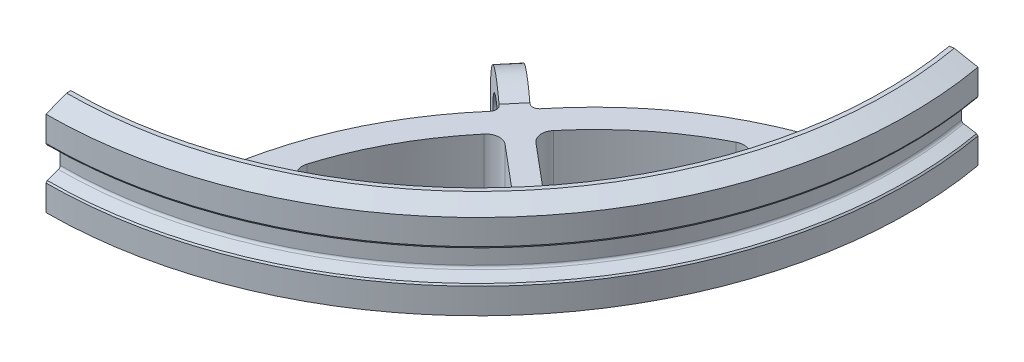
from build123d import *

# Parameters (mm, degrees)
REVOLVE5_ANGLE           = 100
BOSS_EXTRUDE1_DEPTH      = 7.62
BOSS_EXTRUDE1_DEPTH_BACK = 6.35
SKETCH6_R                = 8.382
SKETCH6_R_2              = 4.699
BOSS_EXTRUDE2_DEPTH      = 4.064
SKETCH7_R                = 4.699
CUT_EXTRUDE1_DEPTH       = 4.064
FILLET6_R                = 2.54
FILLET7_R                = 1.27


with BuildPart() as part:
    # Sketch2 → Revolve5 (revolve)
    with BuildSketch(Plane(origin=(0, 0, 0), x_dir=(0, 0, -1), z_dir=(1, 0, 0))):
        with BuildLine():
            Line((8.30436622, 9.401920301), (7.503364151, 9.401920301))
            Line((7.503364151, 9.401920301), (3.703353764, 7.901920301))
            Line((3.703353764, 7.901920301), (3.703353764, 3.210332207))
            Line((3.703353764, 3.210332207), (3.889015818, 2.888756769))
            Line((3.889015818, 2.888756769), (5.996607163, 2.121657669))
            ThreePointArc((5.996607163, 2.121657669), (6.238990142, 1.935670839), (6.330860906, 1.644294154))
            Line((6.330860906, 1.644294154), (6.330860906, -1.644294154))
            ThreePointArc((6.330860906, -1.644294154), (6.238990142, -1.935670839), (5.996607163, -2.121657669))
            Line((5.996607163, -2.121657669), (3.942036829, -2.869458735))
            Line((3.942036829, -2.869458735), (3.703353764, -3.1539083))
            Line((3.703353764, -3.1539083), (3.703353764, -7.901919468))
            Line((3.703353764, -7.901919468), (7.503364151, -9.401919468))
            Line((7.503364151, -9.401919468), (8.30436622, -9.401919468))
            Line((8.30436622, -9.401919468), (8.30436622, 9.401920301))
        make_face()
    revolve(axis=Axis((0, 6.004859942, -83.82), (0, 1, 0)), revolution_arc=REVOLVE5_ANGLE)

    # Sketch4 → Boss-Extrude1 (add, two sides)
    with BuildSketch(Plane(origin=(0, 0, 0), x_dir=(1, 0, 0), z_dir=(0, 1, 0))) as boss_extrude1_sk:
        with BuildLine():
            Line((37.417421774, 49.90058294), (41.308927545, 46.635221882))
            add(Edge.make_bspline(
                [(41.308927545, 46.635221882), (32.170711492, 36.4096748), (26.658447557, 24.604607557), (24.773254773, 11.221353761)],
                knots=[0, 0, 0, 0, 0.951229672, 0.951229672, 0.951229672, 0.951229672], degree=3))
            Line((24.773254773, 11.221353761), (30.296900055, 13.513957683))
            add(Edge.make_bspline(
                [(45.20915346, 43.362543756), (45.181060483, 43.334450618), (45.152967507, 43.30635748), (45.12487453, 43.278264343), (45.120167128, 43.273556913), (45.110752323, 43.264142054), (45.096622576, 43.249997641), (45.087753351, 43.240067133), (45.083318739, 43.23510188), (45.081823118, 43.233427295), (45.078831877, 43.230078124), (45.074345912, 43.225053568), (45.071355487, 43.221703669), (45.069860356, 43.220028647), (44.543381219, 42.630204625), (43.497129316, 41.41698884), (41.520341706, 38.954113502), (39.244432872, 35.779454597), (36.845990391, 31.844372665), (34.77283803, 27.776239692), (33.021954508, 23.571346516), (31.59007601, 19.218336773), (30.754134649, 15.840828784), (30.371469382, 13.909635499), (30.296900055, 13.513957683)],
                knots=[0, 0, 0, 0, 0.003266089, 0.003266089, 0.003266089, 0.003813371, 0.004360654, 0.004907936, 0.004907936, 0.004907936, 0.005092513, 0.00527709, 0.005461667, 0.005461667, 0.005461667, 0.070456558, 0.136558997, 0.268763875, 0.400968753, 0.533173631, 0.665378509, 0.797583388, 0.929788266, 0.96369623, 0.96369623, 0.96369623, 0.96369623], degree=3))
            Line((45.20915346, 43.362543756), (57.169244577, 33.32683571))
            Line((57.169244577, 33.32683571), (59.781533423, 36.440040327))
            Line((59.781533423, 36.440040327), (47.821442306, 46.475748373))
            add(Edge.make_bspline(
                [(47.821442306, 46.475748373), (47.844230351, 46.508292876), (47.867018397, 46.54083738), (47.889806443, 46.573381883), (47.893624924, 46.578835206), (47.901261886, 46.589741852), (47.91273781, 46.606113088), (47.920977325, 46.616571984), (47.925097083, 46.621801431), (47.926486516, 46.623565119), (47.929265381, 46.627092494), (47.933434624, 46.632382812), (47.936214348, 46.63590951), (47.937604296, 46.637672791), (48.427045423, 47.258575393), (49.440149998, 48.499605089), (51.522343159, 50.874034668), (54.25356444, 53.666641066), (57.71237847, 56.711965623), (61.358708232, 59.460046018), (65.1956819, 61.914501723), (69.233916553, 64.080518978), (72.295839262, 65.437471032), (74.003799194, 66.106343688), (74.255456821, 66.203075194)],
                knots=[0, 0, 0, 0, 0.003266089, 0.003266089, 0.003266089, 0.003813371, 0.004360654, 0.004907936, 0.004907936, 0.004907936, 0.005092513, 0.00527709, 0.005461667, 0.005461667, 0.005461667, 0.070456558, 0.136558997, 0.268763875, 0.400968753, 0.533173631, 0.665378509, 0.797583388, 0.929788266, 0.952525748, 0.952525748, 0.952525748, 0.952525748], degree=3))
            Line((74.255456821, 66.203075194), (75.540210442, 72.055852466))
            add(Edge.make_bspline(
                [(43.921216391, 49.748426499), (52.319625597, 60.415556568), (62.859652196, 67.851796539), (75.540210442, 72.055852466)],
                knots=[0, 0, 0, 0, 0.941703848, 0.941703848, 0.941703848, 0.941703848], degree=3))
            Line((43.921216391, 49.748426499), (40.02971062, 53.013787556))
            Line((40.02971062, 53.013787556), (37.417421774, 49.90058294))
        make_face()
    extrude(amount=BOSS_EXTRUDE1_DEPTH)
    extrude(boss_extrude1_sk.sketch, amount=-BOSS_EXTRUDE1_DEPTH_BACK)

    # Sketch6 → Boss-Extrude2 (add)
    with BuildSketch(Plane(origin=(40.031217814, 0, -47.707347646), x_dir=(0.766044443, 0, 0.64278761), z_dir=(-0.64278761, 0, 0.766044443))):
        with Locations((-4.374595424, 0.564027712)):
            Circle(SKETCH6_R)
        with Locations((-4.374595424, 0.564027712)):
            Circle(SKETCH6_R_2, mode=Mode.SUBTRACT)
    extrude(amount=-BOSS_EXTRUDE2_DEPTH)

    # Sketch7 → Cut-Extrude1 (cut)
    with BuildSketch(Plane(origin=(40.031217814, 0, -47.707347646), x_dir=(0.766044443, 0, 0.64278761), z_dir=(-0.64278761, 0, 0.766044443))):
        with Locations((-4.374595424, 0.564027712)):
            Circle(SKETCH7_R)
    extrude(amount=-CUT_EXTRUDE1_DEPTH, mode=Mode.SUBTRACT)

    # Fillet6
    fillet6_edges = [part.edges().sort_by_distance(p)[0] for p in [
        (24.973704771, 3.8099988, -12.553422875),
        (30.543901097, 3.81, -14.757122483),
        (56.587314812, 0.635, -33.815132762),
        (45.20915346, 3.81, -43.362543756),
        (47.821442306, 3.81, -46.475748373),
        (59.195493003, 0.635, -36.931786628),
        (73.345186554, 3.81, -65.845168861),
        (74.53923571, 3.81, -71.715732783),
    ]]
    fillet(fillet6_edges, radius=FILLET6_R)

    # Fillet7
    fillet7_edges = [part.edges().sort_by_distance(p)[0] for p in [
        (41.308927545, 3.81, -46.635221882),
        (43.921216391, 3.81, -49.748426499),
    ]]
    fillet(fillet7_edges, radius=FILLET7_R)


solid = part.part
